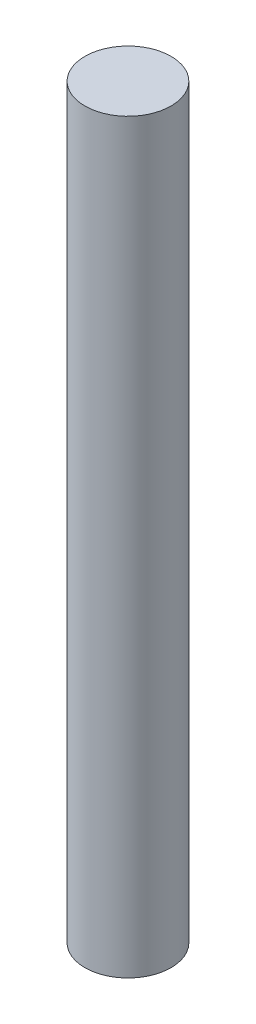
from build123d import *

# Parameters (mm, degrees)
SKETCH1_R           = 1.5
BOSS_EXTRUDE1_DEPTH = 26


with BuildPart() as part:
    # Sketch1 → Boss-Extrude1 (new body)
    with BuildSketch(Plane(origin=(0, 0, 0), x_dir=(1, 0, 0), z_dir=(0, 1, 0))):
        Circle(SKETCH1_R)
    extrude(amount=BOSS_EXTRUDE1_DEPTH)


solid = part.part
